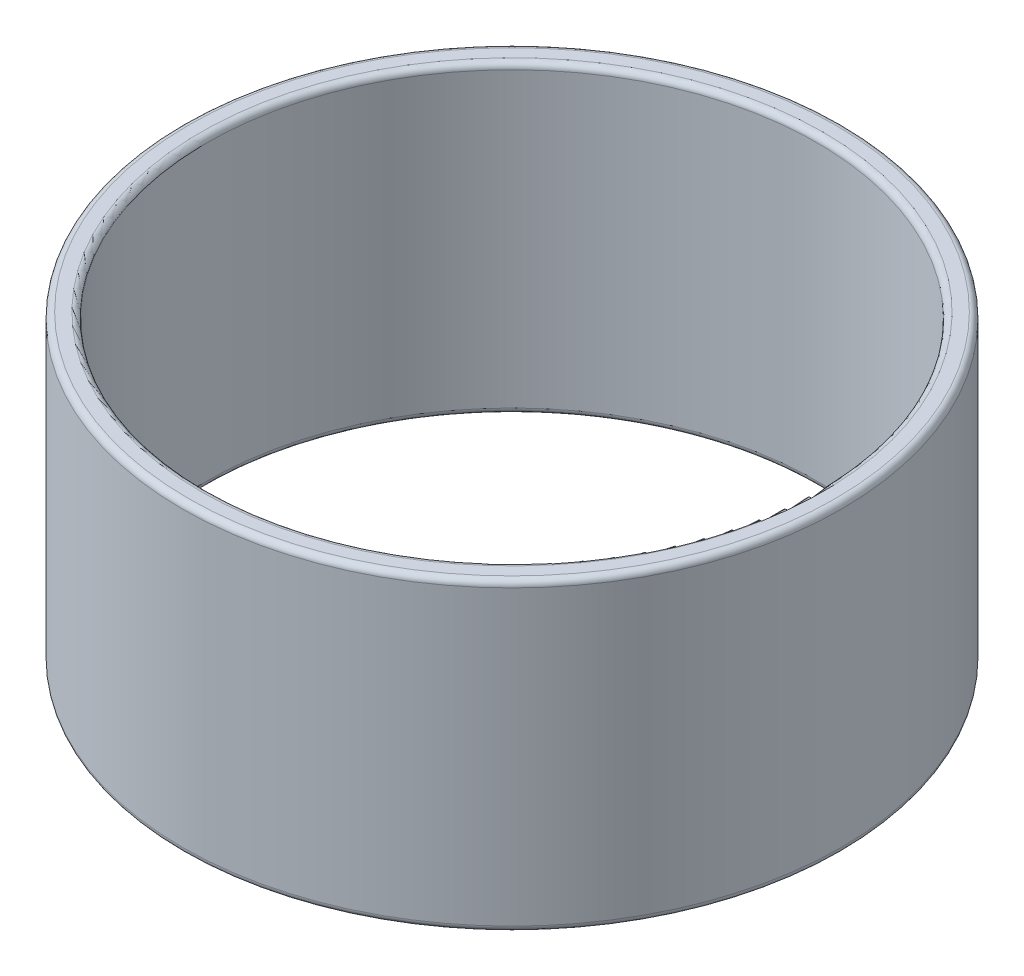
from build123d import *

# Parameters (mm, degrees)
SKETCH_1_R      = 27
SKETCH_1_R_2    = 25
EXTRUDE_1_DEPTH = 25
FILLET_1_R      = 0.5


with BuildPart() as part:
    # Эскиз1 → Бобышка-Вытянуть1 (new body)
    with BuildSketch(Plane(origin=(0, 0, 0), x_dir=(1, 0, 0), z_dir=(0, 1, 0))):
        Circle(SKETCH_1_R)
        Circle(SKETCH_1_R_2, mode=Mode.SUBTRACT)
    extrude(amount=EXTRUDE_1_DEPTH)

    # Скругление1
    fillet_1_edges = [part.edges().sort_by_distance(p)[0] for p in [
        (-27, 0, 0),
        (-27, 25, 0),
        (-25, 0, 0),
        (-25, 25, 0),
    ]]
    fillet(fillet_1_edges, radius=FILLET_1_R)


solid = part.part
